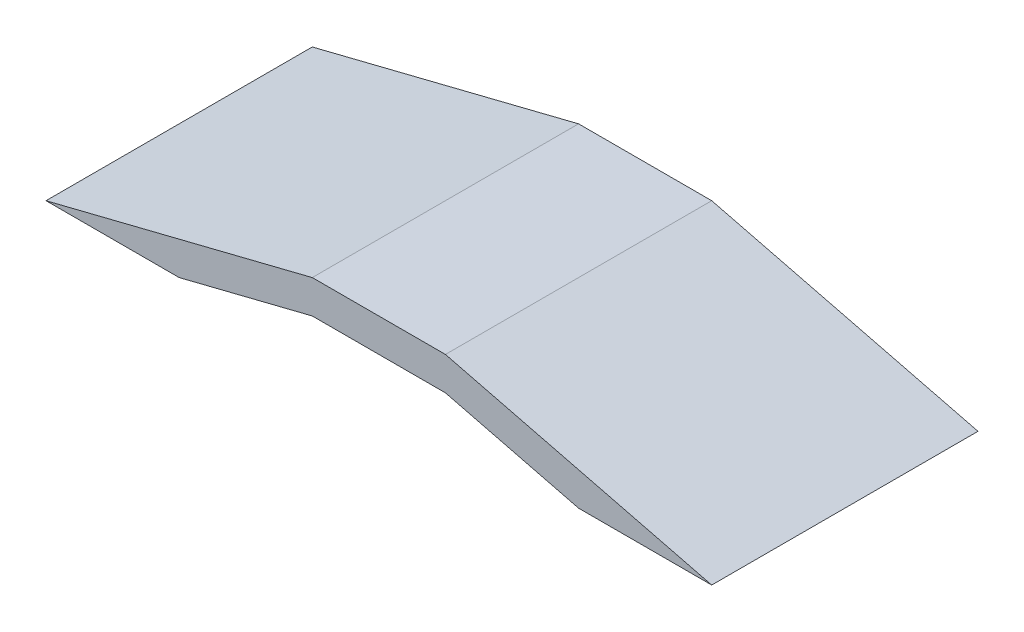
from build123d import *

# Parameters (mm, degrees)
BOSS_EXTRUDE2_DEPTH = 2000


with BuildPart() as part:
    # Sketch1 → Boss-Extrude2 (new body)
    with BuildSketch(Plane.XY):
        Polygon((0, 250), (1000, 0), (2000, 0), (0, 500), (-1000, 500), (-3000, 0), (-2000, 0), (-1000, 250), align=None)
    extrude(amount=-BOSS_EXTRUDE2_DEPTH)


solid = part.part
